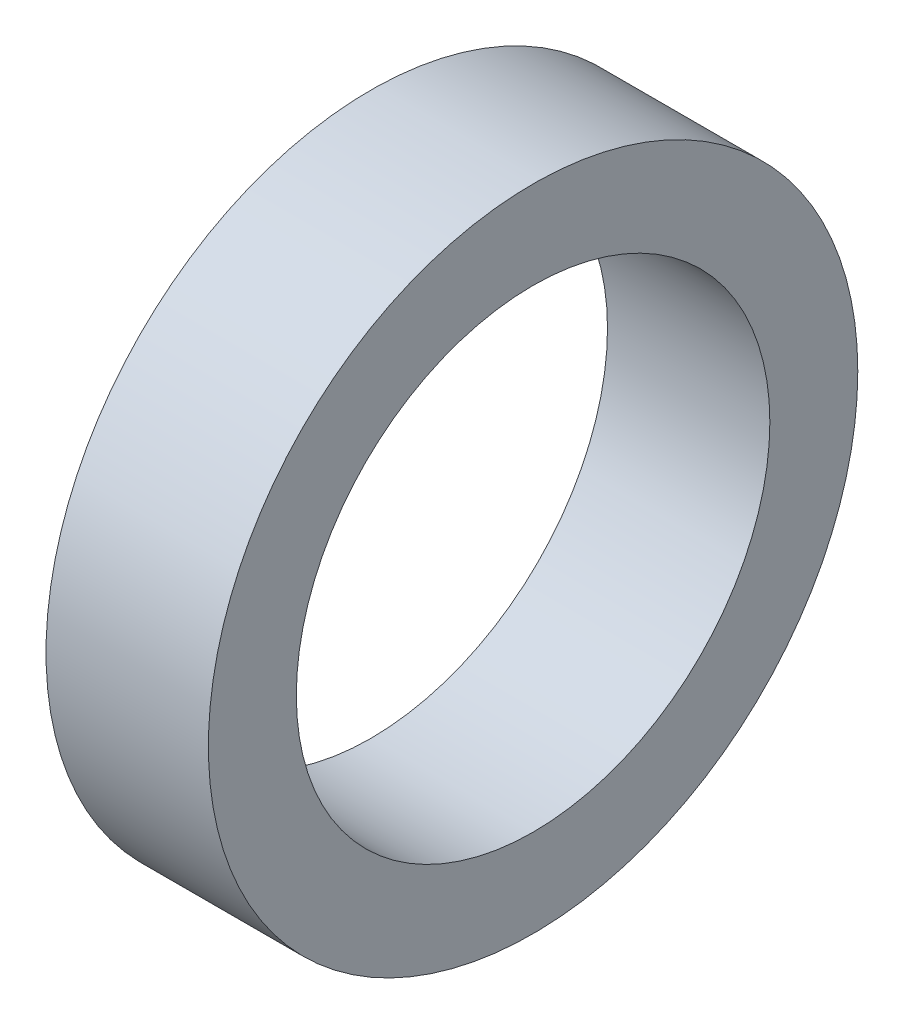
from build123d import *

# Parameters (mm, degrees)
SKETCH_1_R      = 12
SKETCH_1_R_2    = 8.75
EXTRUDE_1_DEPTH = 6


with BuildPart() as part:
    # 草图1 → 凸台-拉伸1 (new body)
    with BuildSketch(Plane(origin=(0, 0, 0), x_dir=(0, 0, -1), z_dir=(1, 0, 0))):
        Circle(SKETCH_1_R)
        Circle(SKETCH_1_R_2, mode=Mode.SUBTRACT)
    extrude(amount=EXTRUDE_1_DEPTH)


solid = part.part
